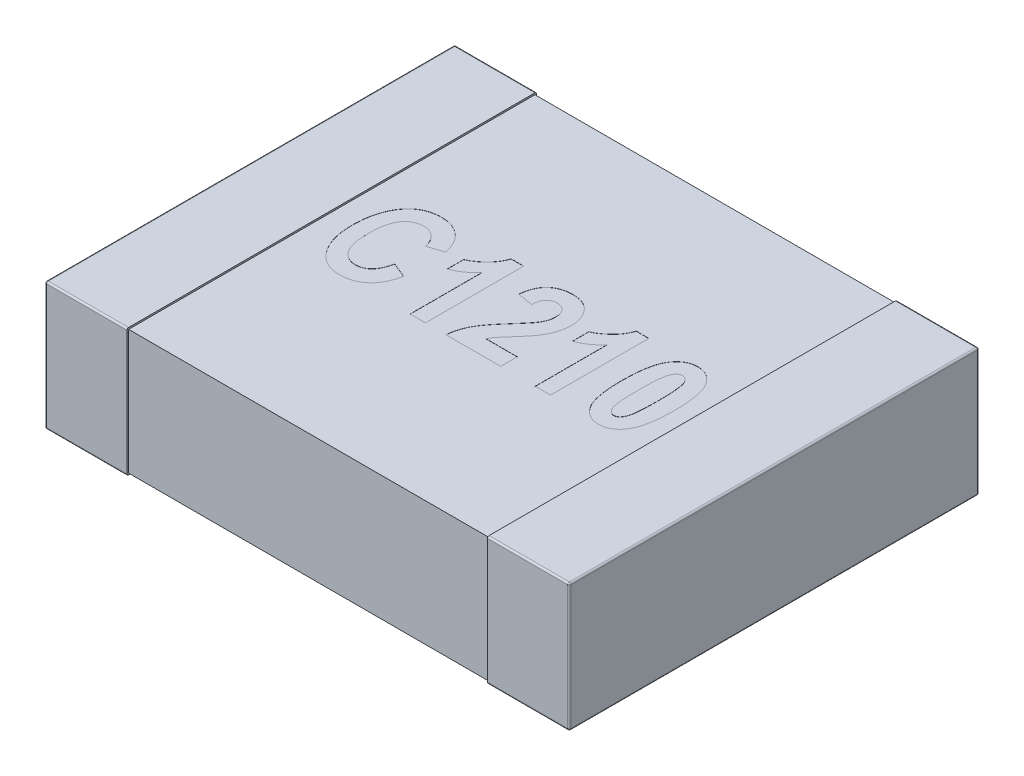
from build123d import *

# Parameters (mm, degrees)
SKETCH1_W            = 0.5
SKETCH1_H            = 2.5
THICKNESS_DEPTH      = 0.78
FILLET1_R            = 0.01
SKETCH2_W            = 2.48
SKETCH2_H            = 0.76
BOSS_EXTRUDE2_DEPTH  = 1.1
FILLET1_OF_MIRROR3_R = 0.01
CUT_EXTRUDE1_DEPTH   = 0.001


with BuildPart() as part:
    # Sketch1 → THICKNESS (new body)
    with BuildSketch(Plane(origin=(0, 0, 0), x_dir=(1, 0, 0), z_dir=(0, 1, 0))):
        with Locations((-1.35, 0)):
            Rectangle(SKETCH1_W, SKETCH1_H)
    thickness = extrude(amount=THICKNESS_DEPTH)

    # Fillet1
    fillet1_edges = [part.edges().sort_by_distance(p)[0] for p in [
        (-1.35, 0.78, -1.25),
        (-1.6, 0.78, 0),
        (-1.35, 0, -1.25),
        (-1.35, 0, 1.25),
        (-1.6, 0, 0),
        (-1.35, 0.78, 1.25),
        (-1.6, 0.39, -1.25),
        (-1.6, 0.39, 1.25),
    ]]
    fillet(fillet1_edges, radius=FILLET1_R)

    # Sketch2 → Boss-Extrude2 (add)
    with BuildSketch(Plane(origin=(0, 0, 0), x_dir=(0, 0, -1), z_dir=(1, 0, 0))):
        with Locations((0, 0.39)):
            Rectangle(SKETCH2_W, SKETCH2_H)
    boss_extrude2 = extrude(amount=-BOSS_EXTRUDE2_DEPTH)

    # Mirror3: THICKNESS, Boss-Extrude2 across plane
    add(thickness.mirror(Plane(origin=(0, 0, 0), x_dir=(0, 0, 1), z_dir=(1, 0, 0))))
    add(boss_extrude2.mirror(Plane(origin=(0, 0, 0), x_dir=(0, 0, 1), z_dir=(1, 0, 0))))

    # Fillet1 of Mirror3
    fillet1_of_mirror3_edges = [part.edges().sort_by_distance(p)[0] for p in [
        (1.35, 0.78, -1.25),
        (1.6, 0.78, 0),
        (1.35, 0, -1.25),
        (1.35, 0, 1.25),
        (1.6, 0, 0),
        (1.35, 0.78, 1.25),
        (1.6, 0.39, -1.25),
        (1.6, 0.39, 1.25),
    ]]
    fillet(fillet1_of_mirror3_edges, radius=FILLET1_OF_MIRROR3_R)

    # Sketch3 → Cut-Extrude1 (cut)
    with BuildSketch(Plane(origin=(0, 0.77, 0), x_dir=(1, 0, 0), z_dir=(0, 1, 0))):
        with BuildLine():
            Line((-0.633766234, -0.081818182), (-0.54025974, -0.120779221))
            add(Edge.make_bspline(
                [(-0.54025974, -0.120779221), (-0.542190916, -0.128639303), (-0.545953907, -0.143955061), (-0.553072968, -0.165845585), (-0.560906681, -0.186156657), (-0.569868889, -0.204774588), (-0.579652323, -0.22186272), (-0.590519728, -0.2372529), (-0.602266644, -0.251023927), (-0.614959883, -0.263143622), (-0.628578862, -0.273571651), (-0.642741192, -0.282864084), (-0.657812589, -0.2904819), (-0.673582011, -0.296913973), (-0.690173435, -0.30169515), (-0.707460803, -0.305293184), (-0.725518316, -0.307352147), (-0.737819635, -0.307643871), (-0.744074675, -0.307792208)],
                knots=[0, 0, 0, 0, 2.4274e-05, 4.7299e-05, 6.9005e-05, 8.9535e-05, 0.000109228, 0.00012801, 0.00014597, 0.000163452, 0.000180548, 0.000197366, 0.000214192, 0.000231126, 0.000248386, 0.000265913, 0.000284051, 0.000302815, 0.000302815, 0.000302815, 0.000302815], degree=3))
            add(Edge.make_bspline(
                [(-0.744074675, -0.307792208), (-0.751922847, -0.307615762), (-0.767297231, -0.307270108), (-0.789731411, -0.303550957), (-0.811079466, -0.297900355), (-0.831302915, -0.289786056), (-0.850425738, -0.279414254), (-0.868245919, -0.266567254), (-0.885179278, -0.251723327), (-0.895024859, -0.240149439), (-0.900040584, -0.234253247)],
                knots=[0, 0, 0, 0, 2.3524e-05, 4.6083e-05, 6.8027e-05, 8.9664e-05, 0.000111294, 0.000133119, 0.000155454, 0.000178649, 0.000178649, 0.000178649, 0.000178649], degree=3))
            add(Edge.make_bspline(
                [(-0.900040584, -0.234253247), (-0.905553874, -0.226973657), (-0.916660907, -0.212308251), (-0.930605169, -0.188125022), (-0.942465032, -0.162144207), (-0.952171745, -0.134342257), (-0.959737616, -0.104688372), (-0.965027142, -0.073168414), (-0.968203664, -0.039797629), (-0.968618829, -0.016930802), (-0.968831169, -0.00523539)],
                knots=[0, 0, 0, 0, 2.7374e-05, 5.5147e-05, 8.3532e-05, 0.000112951, 0.000143367, 0.000175233, 0.000208743, 0.000243825, 0.000243825, 0.000243825, 0.000243825], degree=3))
            add(Edge.make_bspline(
                [(-0.968831169, -0.00523539), (-0.968637181, 0.007110772), (-0.968259326, 0.031159022), (-0.964857312, 0.066170989), (-0.959671088, 0.099178941), (-0.951938643, 0.130060192), (-0.942252052, 0.158992066), (-0.930284297, 0.185794147), (-0.916388532, 0.210746744), (-0.905051176, 0.225649277), (-0.899431818, 0.233035714)],
                knots=[0, 0, 0, 0, 3.7029e-05, 7.2127e-05, 0.000105434, 0.000137178, 0.000167518, 0.000196841, 0.000225141, 0.000252954, 0.000252954, 0.000252954, 0.000252954], degree=3))
            add(Edge.make_bspline(
                [(-0.899431818, 0.233035714), (-0.894329719, 0.239006484), (-0.884274575, 0.250773591), (-0.867087943, 0.266011167), (-0.848624104, 0.278963649), (-0.828889739, 0.289568442), (-0.807796544, 0.297816504), (-0.785447755, 0.303636465), (-0.761753891, 0.307070475), (-0.745547104, 0.307547953), (-0.737256494, 0.307792208)],
                knots=[0, 0, 0, 0, 2.3539e-05, 4.639e-05, 6.8683e-05, 9.1071e-05, 0.000113432, 0.000136466, 0.000160211, 0.000185078, 0.000185078, 0.000185078, 0.000185078], degree=3))
            add(Edge.make_bspline(
                [(-0.737256494, 0.307792208), (-0.73047175, 0.307629806), (-0.717136654, 0.307310613), (-0.697583154, 0.304758839), (-0.678953638, 0.300271901), (-0.661066254, 0.294386439), (-0.644077938, 0.286511751), (-0.627939567, 0.276956277), (-0.612587676, 0.265751432), (-0.603282652, 0.257040711), (-0.598579545, 0.252637987)],
                knots=[0, 0, 0, 0, 2.0351e-05, 3.9998e-05, 5.9017e-05, 7.7767e-05, 9.6399e-05, 0.000115066, 0.000133963, 0.000153275, 0.000153275, 0.000153275, 0.000153275], degree=3))
            add(Edge.make_bspline(
                [(-0.598579545, 0.252637987), (-0.595309521, 0.249244729), (-0.588646132, 0.242330222), (-0.579673863, 0.230683168), (-0.571367098, 0.217856196), (-0.56387477, 0.203794564), (-0.556909391, 0.188635712), (-0.550575652, 0.172301934), (-0.545003727, 0.154756072), (-0.541865499, 0.142589161), (-0.54025974, 0.136363636)],
                knots=[0, 0, 0, 0, 1.4129e-05, 2.879e-05, 4.4021e-05, 5.9928e-05, 7.6544e-05, 9.4044e-05, 0.00011245, 0.000131735, 0.000131735, 0.000131735, 0.000131735], degree=3))
            Line((-0.54025974, 0.136363636), (-0.633766234, 0.105194805))
            add(Edge.make_bspline(
                [(-0.633766234, 0.105194805), (-0.634644909, 0.109185541), (-0.636354666, 0.11695085), (-0.639787422, 0.128157248), (-0.643966666, 0.138565765), (-0.648513738, 0.148426271), (-0.653989169, 0.157397708), (-0.659716643, 0.165908736), (-0.666432642, 0.173449176), (-0.673527909, 0.18041525), (-0.681252714, 0.186435093), (-0.689159747, 0.191879101), (-0.697484746, 0.196405395), (-0.706192985, 0.200045674), (-0.715181323, 0.202991759), (-0.724516737, 0.205063519), (-0.734177863, 0.206318106), (-0.740742924, 0.206434458), (-0.744074675, 0.206493506)],
                knots=[0, 0, 0, 0, 1.2256e-05, 2.3848e-05, 3.5108e-05, 4.5891e-05, 5.6373e-05, 6.6607e-05, 7.6617e-05, 8.6605e-05, 9.6398e-05, 0.000105955, 0.00011538, 0.000124765, 0.000134236, 0.000143718, 0.000153414, 0.000163404, 0.000163404, 0.000163404, 0.000163404], degree=3))
            add(Edge.make_bspline(
                [(-0.744074675, 0.206493506), (-0.748789931, 0.206353704), (-0.758070036, 0.20607856), (-0.77166619, 0.203889452), (-0.784529998, 0.200017532), (-0.79685513, 0.194934464), (-0.808434478, 0.188162303), (-0.819396946, 0.17996112), (-0.829447767, 0.170083071), (-0.839080418, 0.158971961), (-0.84780923, 0.146098344), (-0.855220588, 0.131219865), (-0.861333612, 0.114389642), (-0.866599262, 0.095728379), (-0.870538936, 0.07511347), (-0.873272949, 0.052576839), (-0.874979281, 0.028151167), (-0.875206896, 0.011204229), (-0.875324675, 0.002435065)],
                knots=[0, 0, 0, 0, 1.4142e-05, 2.7833e-05, 4.1163e-05, 5.4369e-05, 6.7734e-05, 8.1297e-05, 9.5333e-05, 0.000109925, 0.000125358, 0.000141856, 0.000159654, 0.000179004, 0.000199969, 0.000222546, 0.000247078, 0.000273384, 0.000273384, 0.000273384, 0.000273384], degree=3))
            add(Edge.make_bspline(
                [(-0.875324675, 0.002435065), (-0.875191591, -0.006657523), (-0.874935311, -0.024167093), (-0.873441403, -0.049456782), (-0.870601838, -0.072692213), (-0.866966979, -0.093964751), (-0.861993016, -0.113150054), (-0.855916359, -0.130259875), (-0.848917017, -0.145461249), (-0.840567553, -0.158554732), (-0.831316181, -0.169858307), (-0.821480281, -0.179672272), (-0.81086996, -0.187870475), (-0.799769071, -0.194818404), (-0.78787285, -0.200083361), (-0.775322035, -0.203665519), (-0.762191061, -0.206143125), (-0.753177467, -0.206375149), (-0.748579545, -0.206493506)],
                knots=[0, 0, 0, 0, 2.728e-05, 5.2532e-05, 7.5955e-05, 9.7474e-05, 0.00011723, 0.00013533, 0.000151887, 0.000167323, 0.000181775, 0.000195636, 0.000208909, 0.000221918, 0.000234837, 0.000247782, 0.000261013, 0.000274791, 0.000274791, 0.000274791, 0.000274791], degree=3))
            add(Edge.make_bspline(
                [(-0.748579545, -0.206493506), (-0.745207358, -0.206389068), (-0.738517882, -0.206181891), (-0.728674261, -0.204862648), (-0.719175332, -0.202503866), (-0.710019814, -0.199231323), (-0.701246726, -0.194913622), (-0.692766059, -0.189798399), (-0.68474913, -0.183649846), (-0.676987921, -0.176668466), (-0.6696677, -0.168638645), (-0.662977578, -0.159406613), (-0.656761698, -0.149137369), (-0.651057639, -0.137767226), (-0.645829022, -0.12536926), (-0.641218918, -0.111848334), (-0.637047202, -0.09727195), (-0.634880955, -0.087068658), (-0.633766234, -0.081818182)],
                knots=[0, 0, 0, 0, 1.0117e-05, 2.007e-05, 2.9726e-05, 3.9431e-05, 4.9178e-05, 5.9013e-05, 6.9094e-05, 7.9438e-05, 9.0298e-05, 0.000101622, 0.000113587, 0.000126274, 0.000139751, 0.00015392, 0.000169106, 0.000185204, 0.000185204, 0.000185204, 0.000185204], degree=3))
        make_face()
        with BuildLine():
            Line((-0.228571429, -0.3), (-0.322077922, -0.3))
            Line((-0.322077922, -0.3), (-0.322077922, 0.136363636))
            add(Edge.make_bspline(
                [(-0.322077922, 0.136363636), (-0.326612967, 0.131604818), (-0.335607023, 0.122166968), (-0.349915904, 0.108991378), (-0.36471966, 0.096844167), (-0.380115976, 0.085670265), (-0.395928681, 0.075363616), (-0.412357817, 0.066060506), (-0.429264072, 0.057741513), (-0.440919313, 0.053015112), (-0.446753247, 0.050649351)],
                knots=[0, 0, 0, 0, 1.9717e-05, 3.9103e-05, 5.8309e-05, 7.7134e-05, 9.6147e-05, 0.000114904, 0.000133744, 0.000152625, 0.000152625, 0.000152625, 0.000152625], degree=3))
            Line((-0.446753247, 0.050649351), (-0.446753247, 0.151948052))
            add(Edge.make_bspline(
                [(-0.446753247, 0.151948052), (-0.440028763, 0.154936711), (-0.426028768, 0.16115893), (-0.405547501, 0.173651852), (-0.384862247, 0.189296604), (-0.367698585, 0.204314334), (-0.35431156, 0.217675635), (-0.344772829, 0.228199307), (-0.336233205, 0.239314774), (-0.328319151, 0.250625264), (-0.321331559, 0.262454223), (-0.315162492, 0.274574568), (-0.309688394, 0.287065361), (-0.306833005, 0.295673212), (-0.305397727, 0.3)],
                knots=[0, 0, 0, 0, 2.2059e-05, 4.5925e-05, 7.1761e-05, 9.98e-05, 0.000114263, 0.00012849, 0.000142372, 0.000156286, 0.00016988, 0.000183547, 0.000197072, 0.000210741, 0.000210741, 0.000210741, 0.000210741], degree=3))
            Line((-0.305397727, 0.3), (-0.228571429, 0.3))
            Line((-0.228571429, 0.3), (-0.228571429, -0.3))
        make_face()
        with BuildLine():
            Line((0.231168831, -0.198701299), (0.231168831, -0.3))
            Line((0.231168831, -0.3), (-0.103896104, -0.3))
            add(Edge.make_bspline(
                [(-0.103896104, -0.3), (-0.102717193, -0.290023127), (-0.100362574, -0.270096487), (-0.093232676, -0.240850191), (-0.083621682, -0.212279158), (-0.073097606, -0.189014511), (-0.062653778, -0.170230077), (-0.053311066, -0.154903506), (-0.042184909, -0.138594465), (-0.029288602, -0.12132505), (-0.014988931, -0.102839355), (0.001030365, -0.083331261), (0.018685858, -0.062783591), (0.031144545, -0.048842236), (0.037581169, -0.04163961)],
                knots=[0, 0, 0, 0, 3.0115e-05, 6.0149e-05, 9.0104e-05, 0.000120454, 0.000136584, 0.000154563, 0.000174284, 0.000195786, 0.000219215, 0.000244392, 0.000271504, 0.000300482, 0.000300482, 0.000300482, 0.000300482], degree=3))
            add(Edge.make_bspline(
                [(0.037581169, -0.04163961), (0.0426279, -0.036010939), (0.052282748, -0.025242788), (0.06586313, -0.009649494), (0.078078642, 0.004372674), (0.088539994, 0.017113192), (0.097615807, 0.028305663), (0.105137428, 0.038120706), (0.111195063, 0.046473236), (0.114432868, 0.051728338), (0.115868506, 0.054058442)],
                knots=[0, 0, 0, 0, 2.2679e-05, 4.3387e-05, 6.2034e-05, 7.8465e-05, 9.284e-05, 0.00010526, 0.000115563, 0.000123772, 0.000123772, 0.000123772, 0.000123772], degree=3))
            add(Edge.make_bspline(
                [(0.115868506, 0.054058442), (0.119200406, 0.060027105), (0.125704348, 0.071678068), (0.132477175, 0.090141083), (0.136904172, 0.108637385), (0.137411483, 0.121079679), (0.137662338, 0.127232143)],
                knots=[0, 0, 0, 0, 2.0477e-05, 3.9971e-05, 5.8816e-05, 7.7249e-05, 7.7249e-05, 7.7249e-05, 7.7249e-05], degree=3))
            add(Edge.make_bspline(
                [(0.137662338, 0.127232143), (0.137446871, 0.133379394), (0.137038978, 0.145016534), (0.133548123, 0.161275597), (0.127712264, 0.175258167), (0.119277109, 0.186610846), (0.109008066, 0.195522263), (0.097163474, 0.202025141), (0.083758289, 0.205877364), (0.074335427, 0.206283998), (0.069480519, 0.206493506)],
                knots=[0, 0, 0, 0, 1.8425e-05, 3.488e-05, 4.9604e-05, 6.3533e-05, 7.6911e-05, 9.0097e-05, 0.000103777, 0.000118317, 0.000118317, 0.000118317, 0.000118317], degree=3))
            add(Edge.make_bspline(
                [(0.069480519, 0.206493506), (0.064215884, 0.206263452), (0.054125287, 0.205822511), (0.039933253, 0.201717312), (0.027615298, 0.194950148), (0.017521106, 0.185128598), (0.009236545, 0.172858222), (0.003255262, 0.157775169), (-0.000845634, 0.140165973), (-0.001990199, 0.127499115), (-0.002597403, 0.120779221)],
                knots=[0, 0, 0, 0, 1.5763e-05, 3.0213e-05, 4.3895e-05, 5.7502e-05, 7.2057e-05, 8.7997e-05, 0.000105893, 0.000126115, 0.000126115, 0.000126115, 0.000126115], degree=3))
            Line((-0.002597403, 0.120779221), (-0.096103896, 0.136363636))
            add(Edge.make_bspline(
                [(-0.096103896, 0.136363636), (-0.095320907, 0.143198959), (-0.093802002, 0.156458675), (-0.089780018, 0.175504415), (-0.085016829, 0.193207573), (-0.079052734, 0.209476529), (-0.071980051, 0.224332506), (-0.063774817, 0.237759127), (-0.05467361, 0.24998232), (-0.044217114, 0.260589096), (-0.032822581, 0.269868633), (-0.020566916, 0.277990701), (-0.007359888, 0.284782282), (0.006683307, 0.290445703), (0.021689768, 0.294638636), (0.037506833, 0.297848518), (0.054259772, 0.299658982), (0.065702003, 0.299884655), (0.071550325, 0.3)],
                knots=[0, 0, 0, 0, 2.0629e-05, 4.0018e-05, 5.8332e-05, 7.5589e-05, 9.1926e-05, 0.000107608, 0.00012273, 0.000137539, 0.000152162, 0.00016675, 0.000181562, 0.000196642, 0.000212095, 0.000228236, 0.000245016, 0.000262559, 0.000262559, 0.000262559, 0.000262559], degree=3))
            add(Edge.make_bspline(
                [(0.071550325, 0.3), (0.077972953, 0.299896568), (0.090421772, 0.299696087), (0.108455332, 0.297094446), (0.125339935, 0.293387656), (0.140909444, 0.287621848), (0.155436067, 0.280686144), (0.168498955, 0.2717074), (0.180633924, 0.261531065), (0.191038037, 0.249449837), (0.200508853, 0.236679923), (0.208640627, 0.223221151), (0.21568143, 0.209430798), (0.221291964, 0.195062253), (0.225659872, 0.180227106), (0.228807663, 0.164956957), (0.230869513, 0.149244657), (0.231068024, 0.138602385), (0.231168831, 0.133198052)],
                knots=[0, 0, 0, 0, 1.9251e-05, 3.7313e-05, 5.4561e-05, 7.1007e-05, 8.7016e-05, 0.000102718, 0.000118433, 0.000134388, 0.000150412, 0.000166093, 0.000181503, 0.000196809, 0.000212296, 0.000227841, 0.000243547, 0.000259752, 0.000259752, 0.000259752, 0.000259752], degree=3))
            add(Edge.make_bspline(
                [(0.231168831, 0.133198052), (0.231066522, 0.127063911), (0.230863408, 0.11488578), (0.228777425, 0.096751019), (0.225696515, 0.078868977), (0.221126279, 0.061215604), (0.215216476, 0.043701097), (0.2080201, 0.026173825), (0.199493051, 0.008576261), (0.191096291, -0.006004365), (0.183572637, -0.018117722), (0.176873054, -0.027800022), (0.169237879, -0.038048541), (0.160881173, -0.049035721), (0.151475268, -0.06055007), (0.141249536, -0.072728613), (0.130168225, -0.085514123), (0.122415247, -0.094167061), (0.118425325, -0.09862013)],
                knots=[0, 0, 0, 0, 1.8395e-05, 3.6519e-05, 5.4695e-05, 7.2797e-05, 9.1162e-05, 0.000110109, 0.000129603, 0.000149779, 0.000160556, 0.000172376, 0.000185087, 0.000198895, 0.000213783, 0.000229684, 0.000246601, 0.000264538, 0.000264538, 0.000264538, 0.000264538], degree=3))
            add(Edge.make_bspline(
                [(0.118425325, -0.09862013), (0.114730773, -0.102717843), (0.107687048, -0.110530203), (0.097640305, -0.12171742), (0.088844904, -0.131980252), (0.080873352, -0.140945199), (0.074074005, -0.148875438), (0.068273523, -0.155672426), (0.063730094, -0.161536281), (0.056848413, -0.170103401), (0.048583791, -0.182162498), (0.042717457, -0.193328186), (0.039894481, -0.198701299)],
                knots=[0, 0, 0, 0, 1.6552e-05, 3.1557e-05, 4.5107e-05, 5.7099e-05, 6.7545e-05, 7.6446e-05, 8.39e-05, 8.9794e-05, 0.000109415, 0.000127615, 0.000127615, 0.000127615, 0.000127615], degree=3))
            Line((0.039894481, -0.198701299), (0.231168831, -0.198701299))
        make_face()
        with BuildLine():
            Line((0.535064935, -0.3), (0.441558442, -0.3))
            Line((0.441558442, -0.3), (0.441558442, 0.136363636))
            add(Edge.make_bspline(
                [(0.441558442, 0.136363636), (0.437023396, 0.131604818), (0.42802934, 0.122166968), (0.41372046, 0.108991378), (0.398916704, 0.096844167), (0.383520388, 0.085670265), (0.367707682, 0.075363616), (0.351278547, 0.066060506), (0.334372292, 0.057741513), (0.322717051, 0.053015112), (0.316883117, 0.050649351)],
                knots=[0, 0, 0, 0, 1.9717e-05, 3.9103e-05, 5.8309e-05, 7.7134e-05, 9.6147e-05, 0.000114904, 0.000133744, 0.000152625, 0.000152625, 0.000152625, 0.000152625], degree=3))
            Line((0.316883117, 0.050649351), (0.316883117, 0.151948052))
            add(Edge.make_bspline(
                [(0.316883117, 0.151948052), (0.323607601, 0.154936711), (0.337607596, 0.16115893), (0.358088863, 0.173651852), (0.378774116, 0.189296604), (0.395937778, 0.204314334), (0.409324804, 0.217675635), (0.418863535, 0.228199307), (0.427403159, 0.239314774), (0.435317213, 0.250625264), (0.442304805, 0.262454223), (0.448473871, 0.274574568), (0.45394797, 0.287065361), (0.456803358, 0.295673212), (0.458238636, 0.3)],
                knots=[0, 0, 0, 0, 2.2059e-05, 4.5925e-05, 7.1761e-05, 9.98e-05, 0.000114263, 0.00012849, 0.000142372, 0.000156286, 0.00016988, 0.000183547, 0.000197072, 0.000210741, 0.000210741, 0.000210741, 0.000210741], degree=3))
            Line((0.458238636, 0.3), (0.535064935, 0.3))
            Line((0.535064935, 0.3), (0.535064935, -0.3))
        make_face()
        with BuildLine():
            add(Edge.make_bspline(
                [(0.834821429, 0.3), (0.840639549, 0.299786151), (0.852119959, 0.299364179), (0.868870196, 0.296120075), (0.884816365, 0.290849583), (0.899848298, 0.283372759), (0.913975177, 0.273742701), (0.927232494, 0.262018149), (0.93963064, 0.248204127), (0.951249349, 0.232176654), (0.961690305, 0.21343172), (0.970607586, 0.191631995), (0.978096632, 0.16670221), (0.984199116, 0.138645389), (0.989040033, 0.107421669), (0.992318364, 0.073028189), (0.99440559, 0.035496593), (0.994668503, 0.009418597), (0.994805195, -0.00413961)],
                knots=[0, 0, 0, 0, 1.7445e-05, 3.4423e-05, 5.0979e-05, 6.7695e-05, 8.4613e-05, 0.000102126, 0.00012066, 0.000140192, 0.000161396, 0.000184866, 0.000210709, 0.000239393, 0.00027094, 0.000305443, 0.000343, 0.000383672, 0.000383672, 0.000383672, 0.000383672], degree=3))
            add(Edge.make_bspline(
                [(0.994805195, -0.00413961), (0.994668204, -0.017657177), (0.994404746, -0.043653951), (0.992322178, -0.081064805), (0.989025436, -0.115373811), (0.984223845, -0.146524997), (0.978048119, -0.174561502), (0.970664653, -0.199485986), (0.961654104, -0.221248543), (0.951260608, -0.239977061), (0.939620342, -0.255951409), (0.927357199, -0.269848432), (0.914093227, -0.28153441), (0.899993331, -0.291128283), (0.885034891, -0.298675251), (0.869184921, -0.303869744), (0.852531336, -0.307180087), (0.841127957, -0.307585376), (0.835308442, -0.307792208)],
                knots=[0, 0, 0, 0, 4.055e-05, 7.7986e-05, 0.000112368, 0.000143915, 0.00017248, 0.000198439, 0.000221797, 0.000243001, 0.000262533, 0.000280985, 0.000298498, 0.000315417, 0.000332024, 0.000348579, 0.000365318, 0.000382763, 0.000382763, 0.000382763, 0.000382763], degree=3))
            add(Edge.make_bspline(
                [(0.835308442, -0.307792208), (0.8294928, -0.307564698), (0.818024707, -0.307116062), (0.80124604, -0.30407122), (0.785311417, -0.298758917), (0.770317119, -0.291275468), (0.756153692, -0.281791071), (0.742903146, -0.27017702), (0.73048827, -0.256496252), (0.721050008, -0.243476526), (0.713953091, -0.231965914), (0.709002311, -0.22233816), (0.704387977, -0.211910954), (0.699946472, -0.200743208), (0.696140585, -0.188616437), (0.692469036, -0.175760617), (0.689173157, -0.162072631), (0.686329292, -0.147594899), (0.68354834, -0.132357973), (0.681481219, -0.11625025), (0.679435846, -0.099381752), (0.678078622, -0.081624149), (0.67680789, -0.063120957), (0.676025038, -0.043754257), (0.675322033, -0.023625146), (0.675323784, -0.009903297), (0.675324675, -0.002922078)],
                knots=[0, 0, 0, 0, 1.7445e-05, 3.4401e-05, 5.0957e-05, 6.7673e-05, 8.4523e-05, 0.000101956, 0.000120399, 0.000139833, 0.000150107, 0.000160943, 0.00017228, 0.000184308, 0.000196975, 0.000210388, 0.000224415, 0.000239196, 0.000254649, 0.000270869, 0.000287904, 0.000305619, 0.000324287, 0.000343543, 0.000363763, 0.000384705, 0.000384705, 0.000384705, 0.000384705], degree=3))
            add(Edge.make_bspline(
                [(0.675324675, -0.002922078), (0.675461269, 0.01055498), (0.675723933, 0.036470786), (0.67781104, 0.073759158), (0.681087742, 0.107909664), (0.685937939, 0.138929923), (0.692056126, 0.166858002), (0.69949056, 0.191726639), (0.708473351, 0.213457046), (0.71886983, 0.232184686), (0.73050939, 0.248159242), (0.742772705, 0.262056214), (0.756036635, 0.273742204), (0.770136541, 0.283336075), (0.785094978, 0.290883043), (0.80094495, 0.296077536), (0.817598534, 0.299387879), (0.829001913, 0.299793168), (0.834821429, 0.3)],
                knots=[0, 0, 0, 0, 4.0429e-05, 7.7743e-05, 0.000112004, 0.00014331, 0.000171875, 0.000197718, 0.000221075, 0.000242279, 0.000261811, 0.000280264, 0.000297777, 0.000314695, 0.000331302, 0.000347858, 0.000364597, 0.000382042, 0.000382042, 0.000382042, 0.000382042], degree=3))
        make_face()
        with BuildLine():
            add(Edge.make_bspline(
                [(0.835064935, 0.206493506), (0.832902572, 0.206369131), (0.828592009, 0.206121196), (0.822323332, 0.20434285), (0.816358561, 0.201513436), (0.810810824, 0.197395243), (0.805718626, 0.192042911), (0.80082867, 0.185695005), (0.796332499, 0.178168087), (0.792015431, 0.169277365), (0.788346845, 0.158113031), (0.785116146, 0.144189602), (0.782574659, 0.127122274), (0.780448056, 0.106929026), (0.778600606, 0.083629224), (0.777481531, 0.057152016), (0.776740649, 0.027561143), (0.776663765, 0.006778146), (0.776623377, -0.00413961)],
                knots=[0, 0, 0, 0, 6.482e-06, 1.2921e-05, 1.9401e-05, 2.6195e-05, 3.3514e-05, 4.1501e-05, 5.0188e-05, 5.9772e-05, 7.1092e-05, 8.5356e-05, 0.000102611, 0.000122819, 0.000146267, 0.000172715, 0.00020231, 0.000235063, 0.000235063, 0.000235063, 0.000235063], degree=3))
            add(Edge.make_bspline(
                [(0.776623377, -0.00413961), (0.776663037, -0.015057399), (0.776738386, -0.035799886), (0.777486292, -0.065349798), (0.778591388, -0.09174693), (0.78046693, -0.115044026), (0.782552359, -0.135201319), (0.785127883, -0.152264915), (0.788353816, -0.166145204), (0.791982454, -0.177288244), (0.796363336, -0.186108869), (0.800833094, -0.193602889), (0.805676125, -0.199958855), (0.810853455, -0.205185653), (0.816353785, -0.209310373), (0.822324571, -0.212133831), (0.828591698, -0.213913712), (0.832902468, -0.214161442), (0.835064935, -0.214285714)],
                knots=[0, 0, 0, 0, 3.2753e-05, 6.2226e-05, 8.8674e-05, 0.000112001, 0.00013233, 0.000149465, 0.000163729, 0.000175048, 0.000184523, 0.00019321, 0.000201197, 0.000208429, 0.000215223, 0.000221704, 0.000228143, 0.000234624, 0.000234624, 0.000234624, 0.000234624], degree=3))
            add(Edge.make_bspline(
                [(0.835064935, -0.214285714), (0.837267915, -0.214164022), (0.841619265, -0.213923653), (0.847932665, -0.21214069), (0.853905966, -0.209269036), (0.859561473, -0.205237273), (0.864602245, -0.199833245), (0.869604095, -0.193636888), (0.873885556, -0.186035364), (0.878243203, -0.17719904), (0.881935358, -0.166040889), (0.88493197, -0.152071587), (0.887738894, -0.135054321), (0.889810592, -0.114884854), (0.891491825, -0.091619203), (0.892658342, -0.06522896), (0.893386121, -0.035718437), (0.893465032, -0.015016718), (0.893506494, -0.00413961)],
                knots=[0, 0, 0, 0, 6.603e-06, 1.3042e-05, 1.9522e-05, 2.6415e-05, 3.3734e-05, 4.1625e-05, 5.0249e-05, 5.9833e-05, 7.1153e-05, 8.5389e-05, 0.000102663, 0.000122872, 0.000146189, 0.000172638, 0.000202111, 0.000234742, 0.000234742, 0.000234742, 0.000234742], degree=3))
            add(Edge.make_bspline(
                [(0.893506494, -0.00413961), (0.893464705, 0.006778064), (0.893385157, 0.027560907), (0.892662152, 0.057152818), (0.891485738, 0.083623637), (0.889817115, 0.106930756), (0.887738497, 0.127140413), (0.884931731, 0.144157369), (0.881936288, 0.15812766), (0.878240619, 0.16928308), (0.873893302, 0.17812739), (0.869563265, 0.185731569), (0.864643068, 0.192032197), (0.859556905, 0.197441518), (0.853907079, 0.201477692), (0.847932378, 0.204348259), (0.841619339, 0.206131503), (0.83726794, 0.206371833), (0.835064935, 0.206493506)],
                knots=[0, 0, 0, 0, 3.2753e-05, 6.2348e-05, 8.8796e-05, 0.000112235, 0.000132443, 0.000149717, 0.000163953, 0.000175273, 0.000184858, 0.000193482, 0.000201469, 0.000208788, 0.00021568, 0.000222161, 0.0002286, 0.000235203, 0.000235203, 0.000235203, 0.000235203], degree=3))
        make_face(mode=Mode.SUBTRACT)
    extrude(amount=-CUT_EXTRUDE1_DEPTH, mode=Mode.SUBTRACT)


solid = part.part
